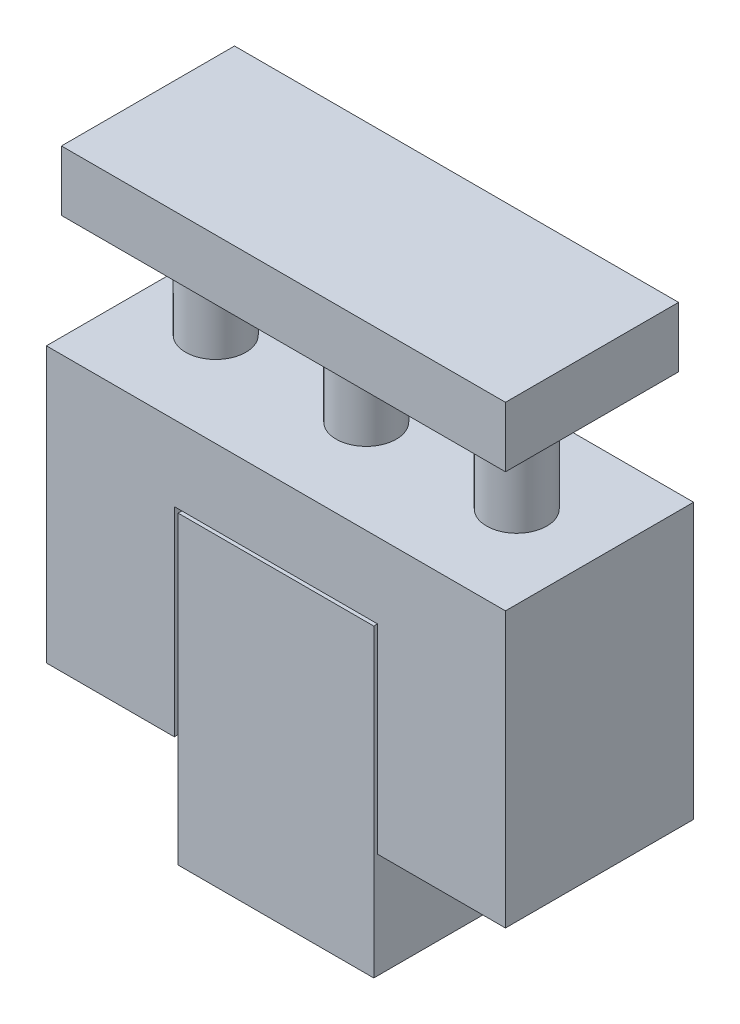
from build123d import *

# Parameters (mm, degrees)
SKETCH_1_W      = 52
SKETCH_1_H      = 81
EXTRUDE_1_DEPTH = 50
EXTRUDE_2_DEPTH = 50
SKETCH_3_R      = 8
EXTRUDE_3_DEPTH = 30
SKETCH_4_W      = 118
SKETCH_4_H      = 46
EXTRUDE_4_DEPTH = 16


with BuildPart() as part:
    # 草图1 → 凸台-拉伸1 (new body)
    with BuildSketch(Plane.XY):
        Rectangle(SKETCH_1_W, SKETCH_1_H)
    extrude(amount=EXTRUDE_1_DEPTH)


with BuildPart() as body_2:
    # 草图2 → 凸台-拉伸2 (new body)
    with BuildSketch(Plane.XY.offset(50)):
        Polygon((-61, -11.5), (-27, -11.5), (-27, 41.5), (27, 41.5), (27, -11.5), (61, -11.5), (61, 61.5), (-61, 61.5), align=None)
    extrude(amount=-EXTRUDE_2_DEPTH)

    # 草图3 → 凸台-拉伸3 (add)
    with BuildSketch(Plane(origin=(0, 61.5, 0), x_dir=(1, 0, 0), z_dir=(0, 1, 0))):
        with Locations((-41, -25)):
            Circle(SKETCH_3_R)
        with Locations((-1, -25)):
            Circle(SKETCH_3_R)
        with Locations((39, -25)):
            Circle(SKETCH_3_R)
    extrude(amount=EXTRUDE_3_DEPTH)

    # 草图4 → 凸台-拉伸4 (add)
    with BuildSketch(Plane(origin=(0, 91.5, 0), x_dir=(1, 0, 0), z_dir=(0, 1, 0))):
        with Locations((0, -25)):
            Rectangle(SKETCH_4_W, SKETCH_4_H)
    extrude(amount=EXTRUDE_4_DEPTH)


solid = Compound([part.part, body_2.part])
